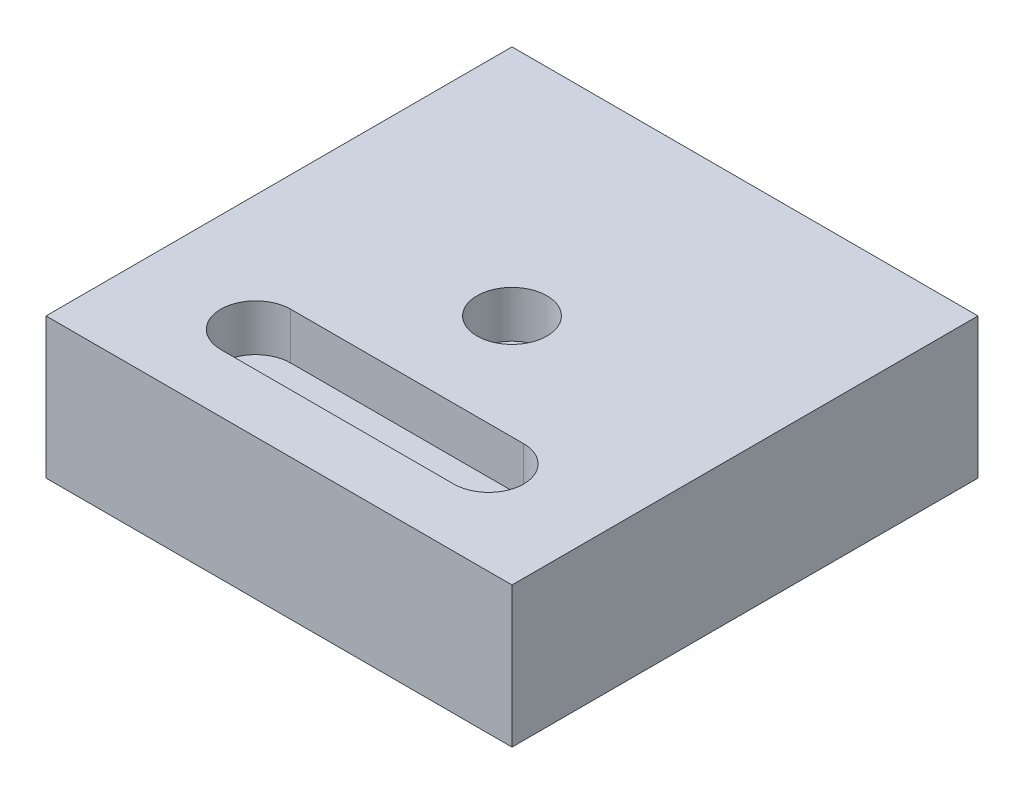
from build123d import *

# Parameters (mm, degrees)
EXTRUDE_1_DEPTH     = 30.144123077
SKETCH_2_W          = 100
SKETCH_2_H          = 100
EXTRUDE_1_2_DEPTH   = 30.144123077
SKETCH_3_R          = 7.5
CUT_EXTRUDE_1_DEPTH = 10
CUT_EXTRUDE_3_DEPTH = 190.231784212


with BuildPart() as part:
    # 草图2 → 凸台-拉伸1 (new body)
    with BuildSketch(Plane(origin=(0, 0, 0), x_dir=(1, 0, 0), z_dir=(0, 1, 0))):
        Polygon((80, 50), (80, -50), (180, -50), align=None)
    extrude(amount=EXTRUDE_1_DEPTH)


with BuildPart() as body_2:
    # 草图2 → Extrude 1 2 (new body)
    with BuildSketch(Plane(origin=(0, 0, 0), x_dir=(1, 0, 0), z_dir=(0, 1, 0))):
        Rectangle(SKETCH_2_W, SKETCH_2_H)
    extrude(amount=EXTRUDE_1_2_DEPTH)

    # 草图3 → 切除-拉伸1 (cut)
    with BuildSketch(Plane(origin=(0, 30.144123077, 0), x_dir=(1, 0, 0), z_dir=(0, 1, 0))):
        Circle(SKETCH_3_R)
        with BuildLine():
            Line((-25, -22.5), (25, -22.5))
            ThreePointArc((25, -22.5), (32.5, -30), (25, -37.5))
            Line((25, -37.5), (-25, -37.5))
            ThreePointArc((-25, -37.5), (-32.5, -30), (-25, -22.5))
        make_face()
    extrude(amount=-CUT_EXTRUDE_1_DEPTH, mode=Mode.SUBTRACT)


with BuildPart() as body_3:
    # 镜向2: mirrored copy
    add(part.part.mirror(Plane(origin=(0, 0, 0), x_dir=(0, 0, 1), z_dir=(1, 0, 0))))


with BuildPart() as cut_extrude_3_tool:
    # 草图6 → 切除-拉伸3 (new, through all)
    with BuildSketch(Plane(origin=(0, 30.144123077, 0), x_dir=(1, 0, 0), z_dir=(0, 1, 0))):
        Polygon((-80, -50), (-80, 50), (-180, -50), align=None)
        Polygon((80, -50), (180, -50), (80, 50), align=None)
    extrude(amount=-CUT_EXTRUDE_3_DEPTH)


with BuildPart() as part_1:
    add(part.part)

    # 切除-拉伸3: cut by cut_extrude_3_tool
    add(cut_extrude_3_tool.part, mode=Mode.SUBTRACT)


with BuildPart() as body_3_1:
    add(body_3.part)

    # 切除-拉伸3: cut by cut_extrude_3_tool
    add(cut_extrude_3_tool.part, mode=Mode.SUBTRACT)


solid = body_2.part
